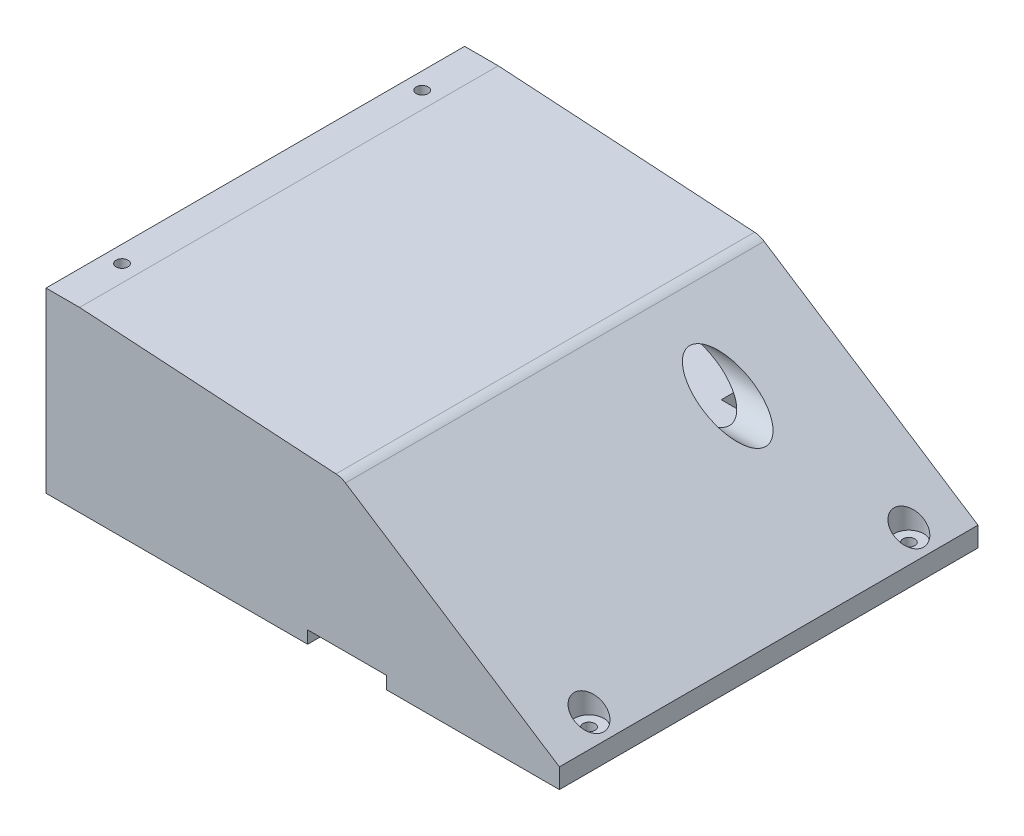
from build123d import *

# Parameters (mm, degrees)
BOSS_EXTRUDE1_DEPTH     = 212
BOSS_EXTRUDE2_DEPTH     = 10
BOSS_EXTRUDE3_DEPTH     = 10
SKETCH4_R               = 3
CUT_EXTRUDE1_DEPTH      = 91
SKETCH6_R               = 7.5
CUT_EXTRUDE2_DEPTH      = 81
SKETCH7_R               = 1.5
SKETCH7_R_2             = 12.5
SKETCH7_W               = 10
SKETCH7_H               = 120
SKETCH7_W_2             = 60
SKETCH7_H_2             = 15
CUT_EXTRUDE3_DEPTH      = 12.5
CUT_EXTRUDE4_REACH      = 112.512
SKETCH8_R               = 12.5
SKETCH9_R               = 3
CUT_EXTRUDE5_DEPTH      = 26
CUT_EXTRUDE5_DEPTH_BACK = 66
SKETCH10_W              = 40
SKETCH10_H              = 6.35
CUT_EXTRUDE6_DEPTH      = 1
CUT_EXTRUDE6_DEPTH_BACK = 213
FILLET1_R               = 10


with BuildPart() as part:
    # Sketch1 → Boss-Extrude1 (new body)
    with BuildSketch(Plane.XY):
        Polygon((0, 0), (-20, 0), (-20, 20), (-242.984559153, 20), (-242.984559153, 25), (-260, 25), (-260, 30), (-49.158083864, 30), (-122.301669645, 77.5), (-242.984559153, 85), (-260, 85), (-260, 90), (-242.984559153, 90), (-110.511971445, 81.767313396), (0, 10), align=None)
    extrude(amount=BOSS_EXTRUDE1_DEPTH)

    # Sketch2 → Boss-Extrude2 (add)
    with BuildSketch(Plane(origin=(0, 0, 0), x_dir=(-1, 0, 0), z_dir=(0, 0, -1))):
        Polygon((0, 0), (260, 0), (260, 90), (110.511971445, 81.767313396), (0, 10), align=None)
    extrude(amount=-BOSS_EXTRUDE2_DEPTH)

    # Sketch3 → Boss-Extrude3 (add)
    with BuildSketch(Plane.XY.offset(212)):
        Polygon((-110.511971445, 81.767313396), (0, 10), (0, 0), (-260, 0), (-260, 90), align=None)
    extrude(amount=-BOSS_EXTRUDE3_DEPTH)

    # Sketch4 → Cut-Extrude1 (cut, through all)
    with BuildSketch(Plane.XZ):
        with Locations((-10, 187)):
            Circle(SKETCH4_R)
        with Locations((-10, 25)):
            Circle(SKETCH4_R)
    extrude(amount=-CUT_EXTRUDE1_DEPTH, mode=Mode.SUBTRACT)

    # Sketch6 → Cut-Extrude2 (cut, through all)
    with BuildSketch(Plane(origin=(0, 10, 0), x_dir=(-1, 0, 0), z_dir=(0, -1, 0))):
        with Locations((10, -25)):
            Circle(SKETCH6_R)
        with Locations((10, -187)):
            Circle(SKETCH6_R)
    extrude(amount=-CUT_EXTRUDE2_DEPTH, mode=Mode.SUBTRACT)

    # Sketch7 → Cut-Extrude3 (cut)
    with BuildSketch(Plane.XZ.offset(-20)):
        with Locations((-161.484559153, 161)):
            Circle(SKETCH7_R)
        with Locations((-225.684559153, 161)):
            Circle(SKETCH7_R)
        with Locations((-161.484559153, 51)):
            Circle(SKETCH7_R)
        with Locations((-225.684559153, 51)):
            Circle(SKETCH7_R)
        with Locations((-67.984559153, 136)):
            Circle(SKETCH7_R_2)
        with Locations((-92.099111311, 106)):
            Rectangle(SKETCH7_W, SKETCH7_H)
        with Locations((-70, 22.5)):
            Rectangle(SKETCH7_W_2, SKETCH7_H_2)
    extrude(amount=-CUT_EXTRUDE3_DEPTH, mode=Mode.SUBTRACT)

    # Sketch8 → Cut-Extrude4 (cut, up to next)
    with BuildSketch(Plane.ZY.offset(110.511971445), mode=Mode.PRIVATE) as cut_extrude4_sk1:
        with Locations((54, 57.25)):
            Circle(SKETCH8_R)
    cut_extrude4_tool1 = extrude(cut_extrude4_sk1.sketch, amount=-CUT_EXTRUDE4_REACH, mode=Mode.PRIVATE) & part.part
    add(cut_extrude4_tool1.solids().sort_by_distance((-110.511971, 57.25, 54))[0], mode=Mode.SUBTRACT)

    # Sketch9 → Cut-Extrude5 (cut, two sides)
    with BuildSketch(Plane.XZ.offset(-25)) as cut_extrude5_sk:
        with Locations((-251.5, 182)):
            Circle(SKETCH9_R)
        with Locations((-251.5, 30)):
            Circle(SKETCH9_R)
    extrude(amount=CUT_EXTRUDE5_DEPTH, mode=Mode.SUBTRACT)
    extrude(cut_extrude5_sk.sketch, amount=-CUT_EXTRUDE5_DEPTH_BACK, mode=Mode.SUBTRACT)

    # Sketch10 → Cut-Extrude6 (cut, two sides)
    with BuildSketch(Plane.XY.offset(212)) as cut_extrude6_sk:
        with Locations((-107.5, 3.175)):
            Rectangle(SKETCH10_W, SKETCH10_H)
    extrude(amount=CUT_EXTRUDE6_DEPTH, mode=Mode.SUBTRACT)
    extrude(cut_extrude6_sk.sketch, amount=-CUT_EXTRUDE6_DEPTH_BACK, mode=Mode.SUBTRACT)

    # Fillet1
    fillet1_edges = [part.edges().sort_by_distance(p)[0] for p in [
        (-110.511971445, 81.767313396, 106),
    ]]
    fillet(fillet1_edges, radius=FILLET1_R)


solid = part.part
